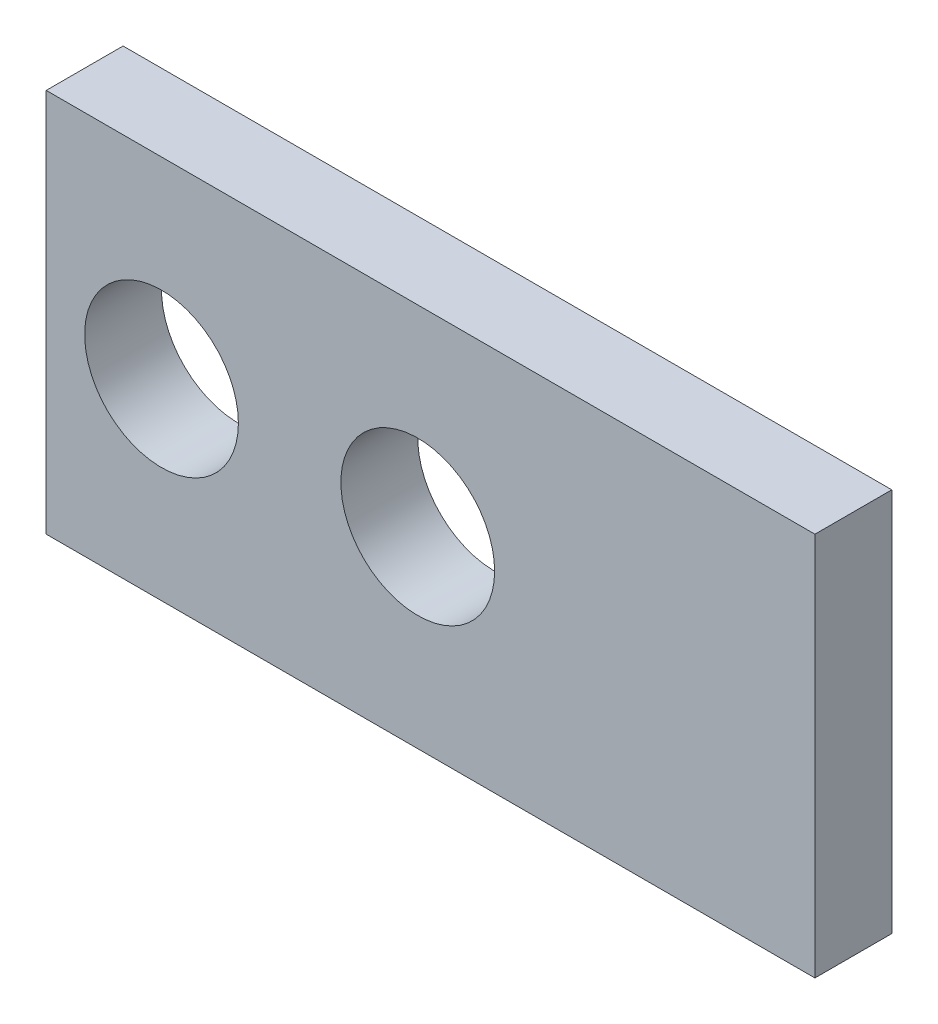
from build123d import *

# Parameters (mm, degrees)
SKETCH1_W           = 100
SKETCH1_H           = 50
BOSS_EXTRUDE1_DEPTH = 10
LPATTERN1_COUNT     = 2
LPATTERN1_PITCH     = 33.333333333


with BuildPart() as part:
    # Sketch1 → Boss-Extrude1 (new body)
    with BuildSketch(Plane.XY):
        Rectangle(SKETCH1_W, SKETCH1_H)
    extrude(amount=BOSS_EXTRUDE1_DEPTH)

    # Sketch2 → Ø20.0mm Dowel Slot1 (revolve, cut)
    with BuildSketch(Plane(origin=(-35, 0, 10), x_dir=(0, -1, 0), z_dir=(1, 0, 0))):
        Polygon((0, 0), (0, 16.00860619), (10, 10), (10, 0), align=None)
    f_20_0mm_dowel_slot1 = revolve(axis=Axis((-35, 0, 16.35), (0, 0, -1)), mode=Mode.SUBTRACT)

    # LPattern1: Ø20.0mm Dowel Slot1 ×2
    with Locations(*[(i * LPATTERN1_PITCH, 0, 0) for i in range(1, LPATTERN1_COUNT)]):
        add(f_20_0mm_dowel_slot1, mode=Mode.SUBTRACT)


solid = part.part
